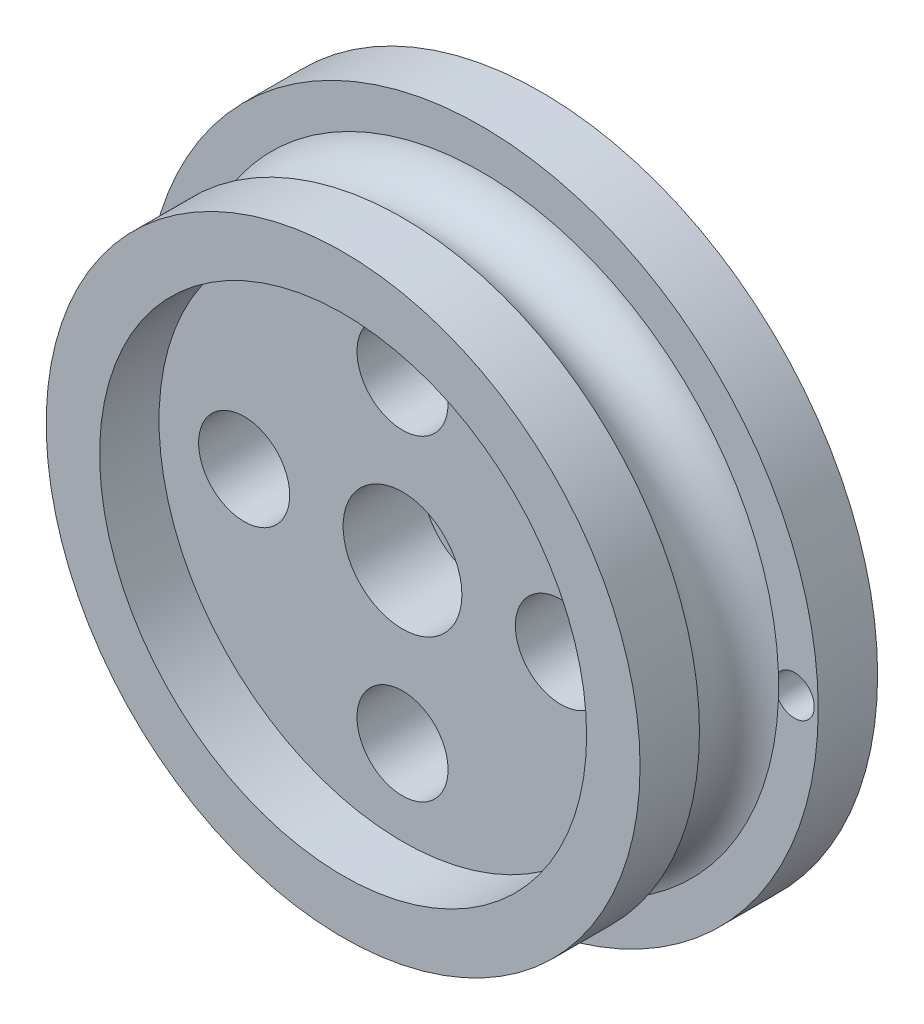
from build123d import *

# Parameters (mm, degrees)
SKETCH2_R           = 15
SKETCH2_R_2         = 3
SKETCH2_R_3         = 2.3
BOSS_EXTRUDE1_DEPTH = 4
SKETCH3_R           = 17
SKETCH3_R_2         = 1.475
SKETCH3_R_3         = 1
BOSS_EXTRUDE2_DEPTH = 3
SKETCH8_R           = 15
SKETCH8_R_2         = 12.3
BOSS_EXTRUDE5_DEPTH = 3


with BuildPart() as part:
    # Sketch2 → Boss-Extrude1 (new body)
    with BuildSketch(Plane.XY):
        Circle(SKETCH2_R)
        Circle(SKETCH2_R_2, mode=Mode.SUBTRACT)
        with Locations((-8, 0)):
            Circle(SKETCH2_R_3, mode=Mode.SUBTRACT)
        with Locations((0, 8)):
            Circle(SKETCH2_R_3, mode=Mode.SUBTRACT)
        with Locations((8, 0)):
            Circle(SKETCH2_R_3, mode=Mode.SUBTRACT)
        with Locations((0, -8)):
            Circle(SKETCH2_R_3, mode=Mode.SUBTRACT)
    extrude(amount=BOSS_EXTRUDE1_DEPTH)

    # Sketch3 → Boss-Extrude2 (add)
    with BuildSketch(Plane.XY):
        Circle(SKETCH3_R)
        Circle(SKETCH3_R_2, mode=Mode.SUBTRACT)
        with Locations((-15.8, 0)):
            Circle(SKETCH3_R_3, mode=Mode.SUBTRACT)
        with Locations((15.8, 0)):
            Circle(SKETCH3_R_3, mode=Mode.SUBTRACT)
    extrude(amount=-BOSS_EXTRUDE2_DEPTH)

    # Sketch7 → Cut-Revolve1 (revolve, cut)
    with BuildSketch(Plane(origin=(0, 0, 0), x_dir=(0, 0, -1), z_dir=(1, 0, 0))):
        with BuildLine():
            Line((-4, 15), (0, 15))
            ThreePointArc((0, 15), (-2, 13.505217823), (-4, 15))
        make_face()
    revolve(axis=Axis((0, 0, 0), (0, 0, 1)), mode=Mode.SUBTRACT)

    # Sketch8 → Boss-Extrude5 (add)
    with BuildSketch(Plane.XY.offset(4)):
        Circle(SKETCH8_R)
        Circle(SKETCH8_R_2, mode=Mode.SUBTRACT)
    extrude(amount=BOSS_EXTRUDE5_DEPTH)


solid = part.part
